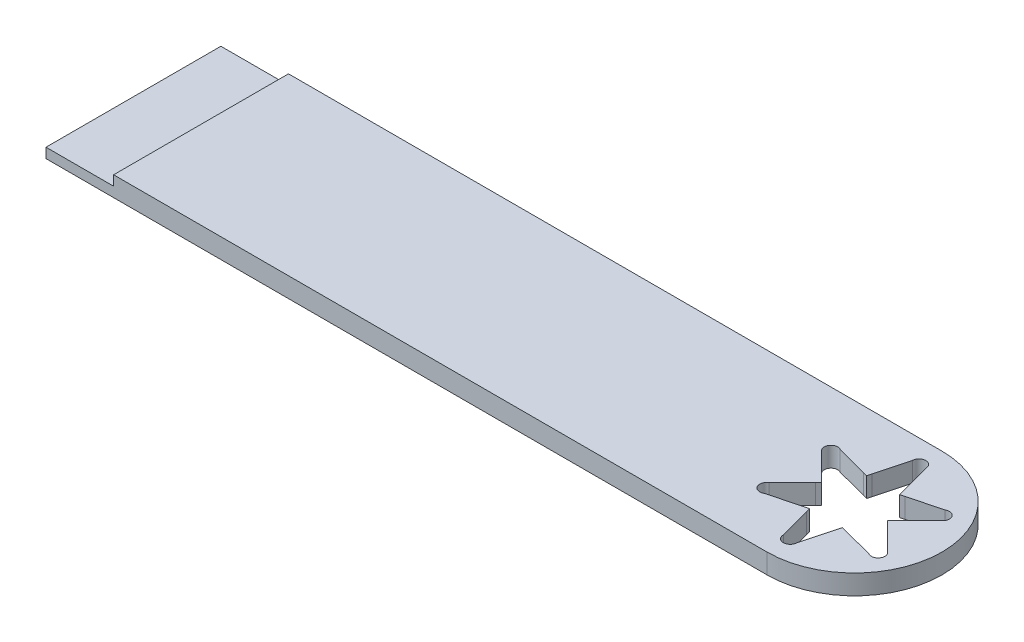
from build123d import *

# Parameters (mm, degrees)
SKETCH_1_R          = 15.8
EXTRUDE_1_DEPTH     = 4.4
CUT_EXTRUDE_2_DEPTH = 4.4
SKETCH_4_R          = 19.4
SKETCH_4_R_2        = 15.8
EXTRUDE_2_DEPTH     = 4.4
EXTRUDE_3_DEPTH     = 4.4
SKETCH_6_W          = 15
SKETCH_6_H          = 38.8
CUT_EXTRUDE_3_DEPTH = 2.2


with BuildPart() as part:
    # 草圖1 → 填料-伸長1 (new body)
    with BuildSketch(Plane(origin=(0, 0, 0), x_dir=(1, 0, 0), z_dir=(0, 1, 0))):
        Circle(SKETCH_1_R)
    extrude(amount=EXTRUDE_1_DEPTH)

    # 草圖3 → 除料-伸長2 (cut)
    with BuildSketch(Plane.XZ):
        with BuildLine():
            Line((-1.5, 14.3), (-3.4, 7.272575881))
            Line((-3.4, 7.272575881), (-3.650072203, 6.322110506))
            Line((-3.650072203, 6.322110506), (-4.598235464, 6.580774314))
            Line((-4.598235464, 6.580774314), (-11.634163274, 8.449038106))
            ThreePointArc((-11.634163274, 8.449038106), (-12.772391842, 8.598888739), (-13.68320138, 7.9))
            ThreePointArc((-13.68320138, 7.9), (-13.833052014, 6.761771432), (-13.134163274, 5.850961894))
            Line((-13.134163274, 5.850961894), (-7.998235464, 0.691801568))
            Line((-7.998235464, 0.691801568), (-7.300144405, 0))
            Line((-7.300144405, 0), (-7.998235464, -0.691801568))
            Line((-7.998235464, -0.691801568), (-13.134163274, -5.850961894))
            ThreePointArc((-13.134163274, -5.850961894), (-13.833052014, -6.761771432), (-13.68320138, -7.9))
            ThreePointArc((-13.68320138, -7.9), (-12.772391842, -8.598888739), (-11.634163274, -8.449038106))
            Line((-11.634163274, -8.449038106), (-4.598235464, -6.580774314))
            Line((-4.598235464, -6.580774314), (-3.650072203, -6.322110506))
            Line((-3.650072203, -6.322110506), (-3.4, -7.272575881))
            Line((-3.4, -7.272575881), (-1.5, -14.3))
            ThreePointArc((-1.5, -14.3), (-1.060660172, -15.360660172), (0, -15.8))
            ThreePointArc((0, -15.8), (1.060660172, -15.360660172), (1.5, -14.3))
            Line((1.5, -14.3), (3.4, -7.272575881))
            Line((3.4, -7.272575881), (3.650072203, -6.322110506))
            Line((3.650072203, -6.322110506), (4.598235464, -6.580774314))
            Line((4.598235464, -6.580774314), (11.634163274, -8.449038106))
            ThreePointArc((11.634163274, -8.449038106), (12.772391842, -8.598888739), (13.68320138, -7.9))
            ThreePointArc((13.68320138, -7.9), (13.833052014, -6.761771432), (13.134163274, -5.850961894))
            Line((13.134163274, -5.850961894), (7.998235464, -0.691801568))
            Line((7.998235464, -0.691801568), (7.300144405, 0))
            Line((7.300144405, 0), (7.998235464, 0.691801568))
            Line((7.998235464, 0.691801568), (13.134163274, 5.850961894))
            ThreePointArc((13.134163274, 5.850961894), (13.833052014, 6.761771432), (13.68320138, 7.9))
            ThreePointArc((13.68320138, 7.9), (12.772391842, 8.598888739), (11.634163274, 8.449038106))
            Line((11.634163274, 8.449038106), (4.598235464, 6.580774314))
            Line((4.598235464, 6.580774314), (3.650072203, 6.322110506))
            Line((3.650072203, 6.322110506), (3.4, 7.272575881))
            Line((3.4, 7.272575881), (1.5, 14.3))
            ThreePointArc((1.5, 14.3), (1.060660172, 15.360660172), (0, 15.8))
            ThreePointArc((0, 15.8), (-1.060660172, 15.360660172), (-1.5, 14.3))
        make_face()
    extrude(amount=-CUT_EXTRUDE_2_DEPTH, mode=Mode.SUBTRACT)

    # 草圖4 → 填料-伸長2 (add)
    with BuildSketch(Plane(origin=(0, 0, 0), x_dir=(1, 0, 0), z_dir=(0, 1, 0))):
        Circle(SKETCH_4_R)
        Circle(SKETCH_4_R_2, mode=Mode.SUBTRACT)
    extrude(amount=EXTRUDE_2_DEPTH)

    # 草圖5 → 填料-伸長3 (add)
    with BuildSketch(Plane(origin=(0, 4.4, 0), x_dir=(1, 0, 0), z_dir=(0, 1, 0))):
        with BuildLine():
            Line((0, 19.4), (-160, 19.4))
            Line((-160, 19.4), (-160, -19.4))
            Line((-160, -19.4), (0, -19.4))
            ThreePointArc((0, -19.4), (-19.4, 0), (0, 19.4))
        make_face()
    extrude(amount=-EXTRUDE_3_DEPTH)

    # 草圖6 → 除料-伸長3 (cut)
    with BuildSketch(Plane(origin=(0, 4.4, 0), x_dir=(1, 0, 0), z_dir=(0, 1, 0))):
        with Locations((-152.5, 0)):
            Rectangle(SKETCH_6_W, SKETCH_6_H)
    extrude(amount=-CUT_EXTRUDE_3_DEPTH, mode=Mode.SUBTRACT)


solid = part.part
